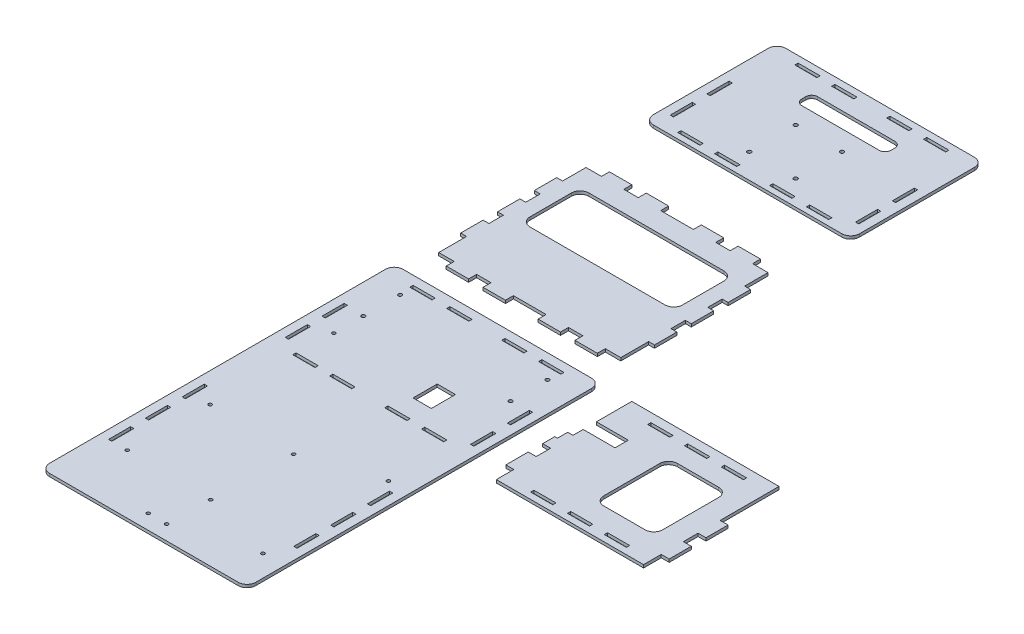
from build123d import *

# Parameters (mm, degrees)
SKETCH1_R             = 1.5875
SKETCH1_R_2           = 1.4478
SKETCH1_W             = 2.794
SKETCH1_H             = 19.05
SKETCH1_W_2           = 19.05
SKETCH1_H_2           = 2.794
SKETCH1_W_3           = 15.748
SKETCH1_H_3           = 20.828
BOSS_EXTRUDE1_DEPTH   = 2.54
BOSS_EXTRUDE1_2_DEPTH = 2.54
BOSS_EXTRUDE1_3_DEPTH = 2.54
SKETCH1_R_3           = 1.65
BOSS_EXTRUDE1_4_DEPTH = 2.54


with BuildPart() as part:
    # Sketch1 → Boss-Extrude1 (new body)
    with BuildSketch(Plane(origin=(0, 0, 0), x_dir=(1, 0, 0), z_dir=(0, 1, 0))):
        with BuildLine():
            Line((-154.654709046, 192.160245655), (7.905290954, 192.160245655))
            ThreePointArc((7.905290954, 192.160245655), (13.293444627, 189.928399328), (15.525290954, 184.540245655))
            Line((15.525290954, 184.540245655), (15.525290954, -105.019754345))
            ThreePointArc((15.525290954, -105.019754345), (13.293444627, -110.407908018), (7.905290954, -112.639754345))
            Line((7.905290954, -112.639754345), (-154.654709046, -112.639754345))
            ThreePointArc((-154.654709046, -112.639754345), (-160.042862719, -110.407908018), (-162.274709046, -105.019754345))
            Line((-162.274709046, -105.019754345), (-162.274709046, 184.540245655))
            ThreePointArc((-162.274709046, 184.540245655), (-160.042862719, 189.928399328), (-154.654709046, 192.160245655))
        make_face()
        with Locations((-136.874709046, 171.840245655)):
            Circle(SKETCH1_R, mode=Mode.SUBTRACT)
        with Locations((-136.874709046, 140.090245655)):
            Circle(SKETCH1_R, mode=Mode.SUBTRACT)
        with Locations((-9.874709046, 171.840245655)):
            Circle(SKETCH1_R, mode=Mode.SUBTRACT)
        with Locations((-9.874709046, 140.090245655)):
            Circle(SKETCH1_R, mode=Mode.SUBTRACT)
        with Locations((-136.874709046, 8.010245655)):
            Circle(SKETCH1_R_2, mode=Mode.SUBTRACT)
        with Locations((-63.849709046, 6.914924606)):
            Circle(SKETCH1_R_2, mode=Mode.SUBTRACT)
        with Locations((-65.596334812, -62.913234459)):
            Circle(SKETCH1_R_2, mode=Mode.SUBTRACT)
        with Locations((-138.621334812, -61.839754345)):
            Circle(SKETCH1_R_2, mode=Mode.SUBTRACT)
        with Locations((-82.264709046, -99.939754345)):
            Circle(SKETCH1_R_2, mode=Mode.SUBTRACT)
        with Locations((-66.389891593, -100.015884724)):
            Circle(SKETCH1_R_2, mode=Mode.SUBTRACT)
        with Locations((-2.950609219, -80.434210103)):
            Circle(SKETCH1_R_2, mode=Mode.SUBTRACT)
        with Locations((-2.950609219, 27.75035927)):
            Circle(SKETCH1_R_2, mode=Mode.SUBTRACT)
        with Locations((-136.874709046, 114.690245655)):
            Circle(SKETCH1_R_2, mode=Mode.SUBTRACT)
        with Locations((-153.257709046, 100.085245655)):
            Rectangle(SKETCH1_W, SKETCH1_H, mode=Mode.SUBTRACT)
        with Locations((6.508290954, 100.085245655)):
            Rectangle(SKETCH1_W, SKETCH1_H, mode=Mode.SUBTRACT)
        with Locations((-153.257709046, -20.564754345)):
            Rectangle(SKETCH1_W, SKETCH1_H, mode=Mode.SUBTRACT)
        with Locations((6.508290954, 131.835245655)):
            Rectangle(SKETCH1_W, SKETCH1_H, mode=Mode.SUBTRACT)
        with Locations((-153.257709046, 131.835245655)):
            Rectangle(SKETCH1_W, SKETCH1_H, mode=Mode.SUBTRACT)
        with Locations((-97.123709046, 82.223972103)):
            Rectangle(SKETCH1_W_2, SKETCH1_H_2, mode=Mode.SUBTRACT)
        with Locations((-128.873709046, 82.223972103)):
            Rectangle(SKETCH1_W_2, SKETCH1_H_2, mode=Mode.SUBTRACT)
        with Locations((-17.875709046, 82.223972103)):
            Rectangle(SKETCH1_W_2, SKETCH1_H_2, mode=Mode.SUBTRACT)
        with Locations((-49.625709046, 82.223972103)):
            Rectangle(SKETCH1_W_2, SKETCH1_H_2, mode=Mode.SUBTRACT)
        with Locations((-97.123709046, 183.143245655)):
            Rectangle(SKETCH1_W_2, SKETCH1_H_2, mode=Mode.SUBTRACT)
        with Locations((-128.873709046, 183.143245655)):
            Rectangle(SKETCH1_W_2, SKETCH1_H_2, mode=Mode.SUBTRACT)
        with Locations((-17.875709046, 183.143245655)):
            Rectangle(SKETCH1_W_2, SKETCH1_H_2, mode=Mode.SUBTRACT)
        with Locations((-49.625709046, 183.143245655)):
            Rectangle(SKETCH1_W_2, SKETCH1_H_2, mode=Mode.SUBTRACT)
        with Locations((-153.257709046, -52.314754345)):
            Rectangle(SKETCH1_W, SKETCH1_H, mode=Mode.SUBTRACT)
        with Locations((6.508290954, -20.564754345)):
            Rectangle(SKETCH1_W, SKETCH1_H, mode=Mode.SUBTRACT)
        with Locations((6.508290954, -52.314754345)):
            Rectangle(SKETCH1_W, SKETCH1_H, mode=Mode.SUBTRACT)
        with Locations((6.508290954, 11.185245655)):
            Rectangle(SKETCH1_W, SKETCH1_H, mode=Mode.SUBTRACT)
        with Locations((-153.257709046, 11.185245655)):
            Rectangle(SKETCH1_W, SKETCH1_H, mode=Mode.SUBTRACT)
        with Locations((-46.457458115, 110.828903786)):
            Rectangle(SKETCH1_W_3, SKETCH1_H_3, mode=Mode.SUBTRACT)
    extrude(amount=BOSS_EXTRUDE1_DEPTH)


with BuildPart() as body_2:
    # Sketch1 → Boss-Extrude1 2 (new body)
    with BuildSketch(Plane(origin=(0, 0, 0), x_dir=(1, 0, 0), z_dir=(0, 1, 0))):
        Polygon((35.68955395, 109.737245655), (35.68955395, 90.433245655), (42.54755395, 90.433245655), (42.54755395, 75.320245655), (169.54755395, 75.320245655), (169.54755395, 90.560245655), (176.40555395, 90.560245655), (176.40555395, 109.610245655), (169.54755395, 109.610245655), (169.54755395, 122.310245655), (176.40555395, 122.310245655), (176.40555395, 141.360245655), (169.54755395, 141.360245655), (169.54755395, 192.160245655), (42.54755395, 192.160245655), (42.54755395, 161.680245655), (70.03035395, 161.680245655), (70.03035395, 150.250245655), (42.54755395, 150.250245655), (42.54755395, 141.487245655), (37.97555395, 141.487245655), (37.97555395, 132.597245655), (35.68955395, 132.597245655), (35.68955395, 122.183245655), (42.54755395, 122.183245655), (42.54755395, 109.737245655), align=None)
        with Locations((76.20255395, 82.223972103)):
            Rectangle(SKETCH1_W_2, SKETCH1_H_2, mode=Mode.SUBTRACT)
        with BuildLine():
            Line((108.58755395, 165.490245655), (144.14755395, 165.490245655))
            ThreePointArc((144.14755395, 165.490245655), (149.535707623, 163.258399328), (151.76755395, 157.870245655))
            Line((151.76755395, 157.870245655), (151.76755395, 109.610245655))
            ThreePointArc((151.76755395, 109.610245655), (149.535707623, 104.222091982), (144.14755395, 101.990245655))
            Line((144.14755395, 101.990245655), (108.58755395, 101.990245655))
            ThreePointArc((108.58755395, 101.990245655), (103.199400277, 104.222091982), (100.96755395, 109.610245655))
            Line((100.96755395, 109.610245655), (100.96755395, 157.870245655))
            ThreePointArc((100.96755395, 157.870245655), (103.199400277, 163.258399328), (108.58755395, 165.490245655))
        make_face(mode=Mode.SUBTRACT)
        with Locations((76.20255395, 183.143245655)):
            Rectangle(SKETCH1_W_2, SKETCH1_H_2, mode=Mode.SUBTRACT)
        with Locations((139.70255395, 183.143245655)):
            Rectangle(SKETCH1_W_2, SKETCH1_H_2, mode=Mode.SUBTRACT)
        with Locations((107.95255395, 183.143245655)):
            Rectangle(SKETCH1_W_2, SKETCH1_H_2, mode=Mode.SUBTRACT)
        with Locations((139.70255395, 82.223972103)):
            Rectangle(SKETCH1_W_2, SKETCH1_H_2, mode=Mode.SUBTRACT)
        with Locations((107.95255395, 82.223972103)):
            Rectangle(SKETCH1_W_2, SKETCH1_H_2, mode=Mode.SUBTRACT)
    extrude(amount=BOSS_EXTRUDE1_2_DEPTH)


with BuildPart() as body_3:
    # Sketch1 → Boss-Extrude1 3 (new body)
    with BuildSketch(Plane(origin=(0, 0, 0), x_dir=(1, 0, 0), z_dir=(0, 1, 0))):
        Polygon((-106.775709046, 213.232915774), (-87.471709046, 213.232915774), (-87.471709046, 220.090915774), (-59.277709046, 220.090915774), (-59.277709046, 213.232915774), (-39.973709046, 213.232915774), (-39.973709046, 220.090915774), (-27.527709046, 220.090915774), (-27.527709046, 213.232915774), (-8.223709046, 213.232915774), (-8.223709046, 220.090915774), (5.111290954, 220.090915774), (5.111290954, 244.093915774), (10.191290954, 244.093915774), (10.191290954, 263.397915774), (5.111290954, 263.397915774), (5.111290954, 275.843915774), (10.191290954, 275.843915774), (10.191290954, 295.147915774), (5.111290954, 295.147915774), (5.111290954, 307.593915774), (10.191290954, 307.593915774), (10.191290954, 326.897915774), (5.111290954, 326.897915774), (5.111290954, 347.090915774), (-8.223709046, 347.090915774), (-8.223709046, 353.948915774), (-27.527709046, 353.948915774), (-27.527709046, 347.090915774), (-39.973709046, 347.090915774), (-39.973709046, 353.948915774), (-59.277709046, 353.948915774), (-59.277709046, 347.090915774), (-87.471709046, 347.090915774), (-87.471709046, 353.948915774), (-106.775709046, 353.948915774), (-106.775709046, 347.090915774), (-119.221709046, 347.090915774), (-119.221709046, 353.948915774), (-138.525709046, 353.948915774), (-138.525709046, 347.090915774), (-151.860709046, 347.090915774), (-151.860709046, 326.897915774), (-156.940709046, 326.897915774), (-156.940709046, 307.593915774), (-151.860709046, 307.593915774), (-151.860709046, 295.147915774), (-156.940709046, 295.147915774), (-156.940709046, 275.843915774), (-151.860709046, 275.843915774), (-151.860709046, 263.397915774), (-156.940709046, 263.397915774), (-156.940709046, 244.093915774), (-151.860709046, 244.093915774), (-151.860709046, 220.090915774), (-138.525709046, 220.090915774), (-138.525709046, 213.232915774), (-119.221709046, 213.232915774), (-119.221709046, 220.090915774), (-106.775709046, 220.090915774), align=None)
        with BuildLine():
            Line((-131.540709046, 329.310915774), (-15.208709046, 329.310915774))
            ThreePointArc((-15.208709046, 329.310915774), (-9.820555373, 327.079069447), (-7.588709046, 321.690915774))
            Line((-7.588709046, 321.690915774), (-7.588709046, 286.130915774))
            ThreePointArc((-7.588709046, 286.130915774), (-9.820555373, 280.742762102), (-15.208709046, 278.510915774))
            Line((-15.208709046, 278.510915774), (-131.540709046, 278.510915774))
            ThreePointArc((-131.540709046, 278.510915774), (-136.928862719, 280.742762102), (-139.160709046, 286.130915774))
            Line((-139.160709046, 286.130915774), (-139.160709046, 321.690915774))
            ThreePointArc((-139.160709046, 321.690915774), (-136.928862719, 327.079069447), (-131.540709046, 329.310915774))
        make_face(mode=Mode.SUBTRACT)
    extrude(amount=BOSS_EXTRUDE1_3_DEPTH)


with BuildPart() as body_4:
    # Sketch1 → Boss-Extrude1 4 (new body)
    with BuildSketch(Plane(origin=(0, 0, 0), x_dir=(1, 0, 0), z_dir=(0, 1, 0))):
        with BuildLine():
            Line((-154.654709046, 407.920332838), (7.905290954, 407.920332838))
            ThreePointArc((7.905290954, 407.920332838), (13.293444627, 410.152179165), (15.525290954, 415.540332838))
            Line((15.525290954, 415.540332838), (15.525290954, 514.600332838))
            ThreePointArc((15.525290954, 514.600332838), (13.293444627, 519.98848651), (7.905290954, 522.220332838))
            Line((7.905290954, 522.220332838), (-154.654709046, 522.220332838))
            ThreePointArc((-154.654709046, 522.220332838), (-160.042862719, 519.98848651), (-162.274709046, 514.600332838))
            Line((-162.274709046, 514.600332838), (-162.274709046, 415.540332838))
            ThreePointArc((-162.274709046, 415.540332838), (-160.042862719, 410.152179165), (-154.654709046, 407.920332838))
        make_face()
        with Locations((-93.180470349, 469.194747181)):
            Circle(SKETCH1_R_3, mode=Mode.SUBTRACT)
        with Locations((-53.180470349, 469.194747181)):
            Circle(SKETCH1_R_3, mode=Mode.SUBTRACT)
        with Locations((-53.180470349, 429.194747181)):
            Circle(SKETCH1_R_3, mode=Mode.SUBTRACT)
        with Locations((-93.180470349, 429.194747181)):
            Circle(SKETCH1_R_3, mode=Mode.SUBTRACT)
        with Locations((-153.257709046, 432.027278616)):
            Rectangle(SKETCH1_W, SKETCH1_H, mode=Mode.SUBTRACT)
        with Locations((6.508290954, 432.027278616)):
            Rectangle(SKETCH1_W, SKETCH1_H, mode=Mode.SUBTRACT)
        with Locations((6.508290954, 463.777278616)):
            Rectangle(SKETCH1_W, SKETCH1_H, mode=Mode.SUBTRACT)
        with Locations((-153.257709046, 463.777278616)):
            Rectangle(SKETCH1_W, SKETCH1_H, mode=Mode.SUBTRACT)
        with Locations((-97.123709046, 414.166005064)):
            Rectangle(SKETCH1_W_2, SKETCH1_H_2, mode=Mode.SUBTRACT)
        with Locations((-128.873709046, 414.166005064)):
            Rectangle(SKETCH1_W_2, SKETCH1_H_2, mode=Mode.SUBTRACT)
        with Locations((-17.875709046, 414.166005064)):
            Rectangle(SKETCH1_W_2, SKETCH1_H_2, mode=Mode.SUBTRACT)
        with Locations((-49.625709046, 414.166005064)):
            Rectangle(SKETCH1_W_2, SKETCH1_H_2, mode=Mode.SUBTRACT)
        with Locations((-97.123709046, 515.085278616)):
            Rectangle(SKETCH1_W_2, SKETCH1_H_2, mode=Mode.SUBTRACT)
        with Locations((-128.873709046, 515.085278616)):
            Rectangle(SKETCH1_W_2, SKETCH1_H_2, mode=Mode.SUBTRACT)
        with Locations((-17.875709046, 515.085278616)):
            Rectangle(SKETCH1_W_2, SKETCH1_H_2, mode=Mode.SUBTRACT)
        with Locations((-49.625709046, 515.085278616)):
            Rectangle(SKETCH1_W_2, SKETCH1_H_2, mode=Mode.SUBTRACT)
        with BuildLine():
            Line((-104.957102542, 499.837878693), (-38.249150778, 499.837878693))
            ThreePointArc((-38.249150778, 499.837878693), (-34.65704833, 498.349981141), (-33.169150778, 494.757878693))
            Line((-33.169150778, 494.757878693), (-33.169150778, 491.402305469))
            ThreePointArc((-33.169150778, 491.402305469), (-34.65704833, 487.810203021), (-38.249150778, 486.322305469))
            Line((-38.249150778, 486.322305469), (-104.957102542, 486.322305469))
            ThreePointArc((-104.957102542, 486.322305469), (-108.54920499, 487.810203021), (-110.037102542, 491.402305469))
            Line((-110.037102542, 491.402305469), (-110.037102542, 494.757878693))
            ThreePointArc((-110.037102542, 494.757878693), (-108.54920499, 498.349981141), (-104.957102542, 499.837878693))
        make_face(mode=Mode.SUBTRACT)
    extrude(amount=BOSS_EXTRUDE1_4_DEPTH)


solid = Compound([part.part, body_2.part, body_3.part, body_4.part])
